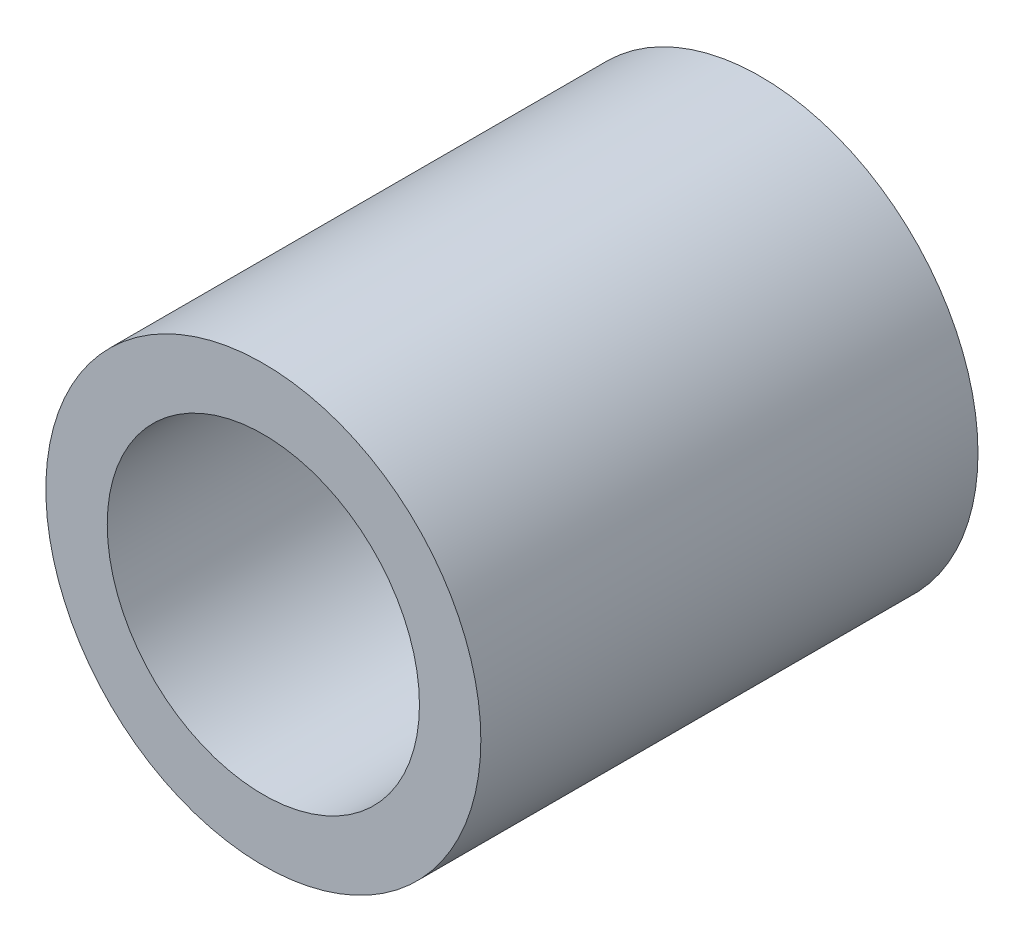
from build123d import *

# Parameters (mm, degrees)
SKETCH1_R      = 5.55625
SKETCH1_R_2    = 3.9878
EXTRUDE1_DEPTH = 6.35


with BuildPart() as part:
    # Sketch1 → Extrude1 (new body, symmetric)
    with BuildSketch(Plane.XY):
        Circle(SKETCH1_R)
        Circle(SKETCH1_R_2, mode=Mode.SUBTRACT)
    extrude(amount=EXTRUDE1_DEPTH, both=True)


solid = part.part
